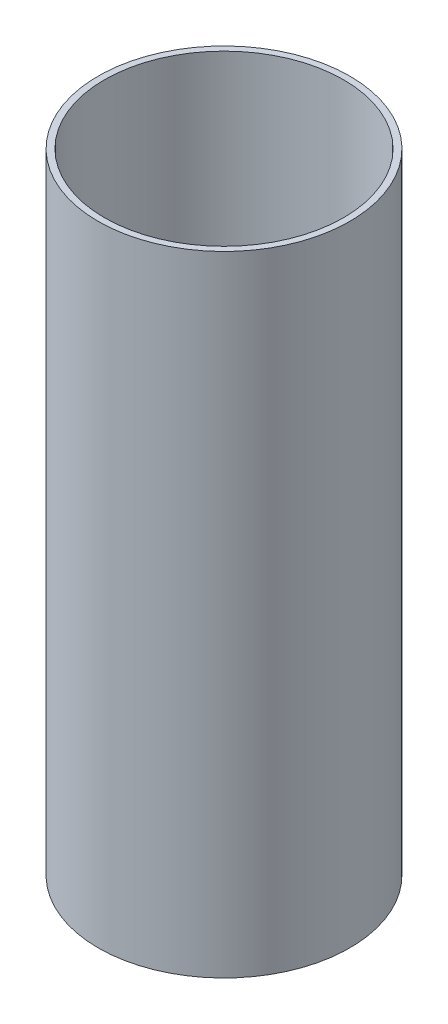
from build123d import *

# Parameters (mm, degrees)
SKETCH_1_R      = 40
SKETCH_1_R_2    = 38
EXTRUDE_1_DEPTH = 200


with BuildPart() as part:
    # 草图1 → 凸台-拉伸1 (new body)
    with BuildSketch(Plane(origin=(0, 0, 0), x_dir=(1, 0, 0), z_dir=(0, 1, 0))):
        Circle(SKETCH_1_R)
        Circle(SKETCH_1_R_2, mode=Mode.SUBTRACT)
    extrude(amount=EXTRUDE_1_DEPTH)


solid = part.part
